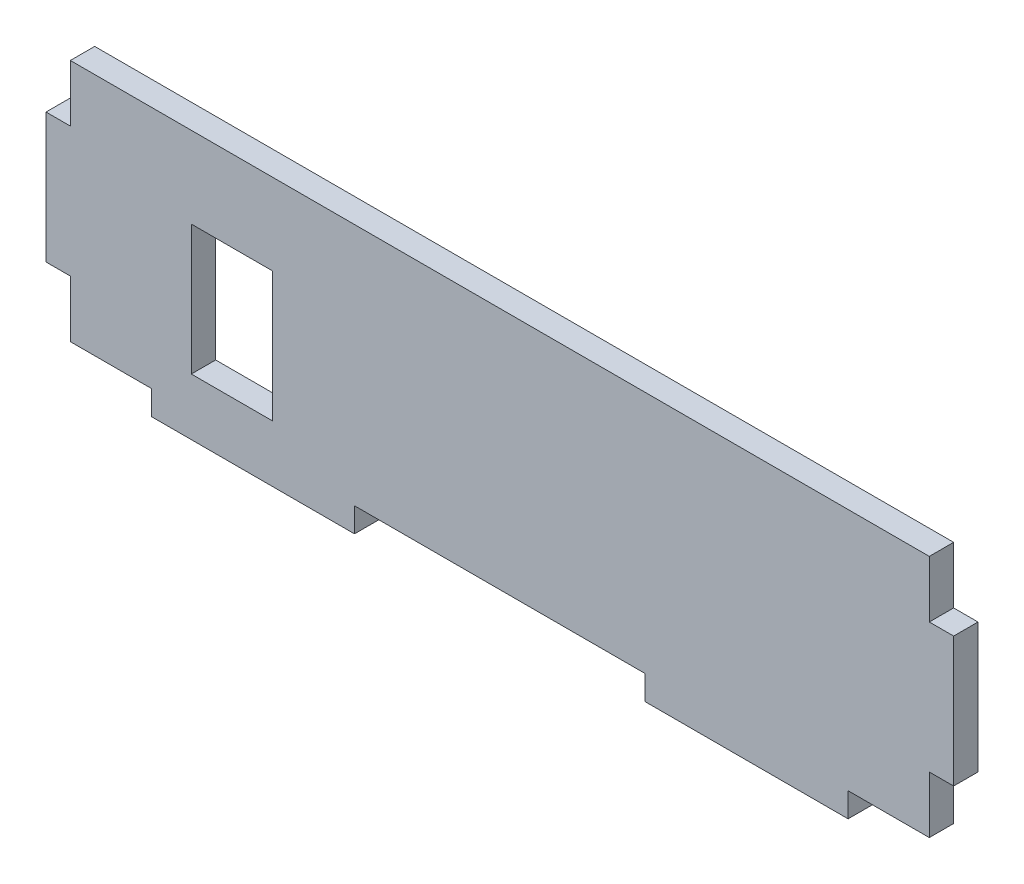
from build123d import *

# Parameters (mm, degrees)
EXTRUDE_1_DEPTH = 3


with BuildPart() as part:
    # 草图2 → 凸台-拉伸1 (new body)
    with BuildSketch(Plane.XY):
        Polygon((41.5, 0), (59.4, 0), (77.3, 0), (77.3, -3), (102.3, -3), (102.3, 0), (112.3, 0), (112.3, 7), (115.3, 7), (115.3, 23), (112.3, 23), (112.3, 30), (6.5, 30), (6.5, 23), (3.5, 23), (3.5, 7), (6.5, 7), (6.5, 0), (16.5, 0), (16.5, -3), (41.5, -3), align=None)
        Polygon((26.4, 4), (21.4, 4), (21.4, 20), (26.4, 20), (31.4, 20), (31.4, 4), align=None, mode=Mode.SUBTRACT)
    extrude(amount=EXTRUDE_1_DEPTH)


solid = part.part
